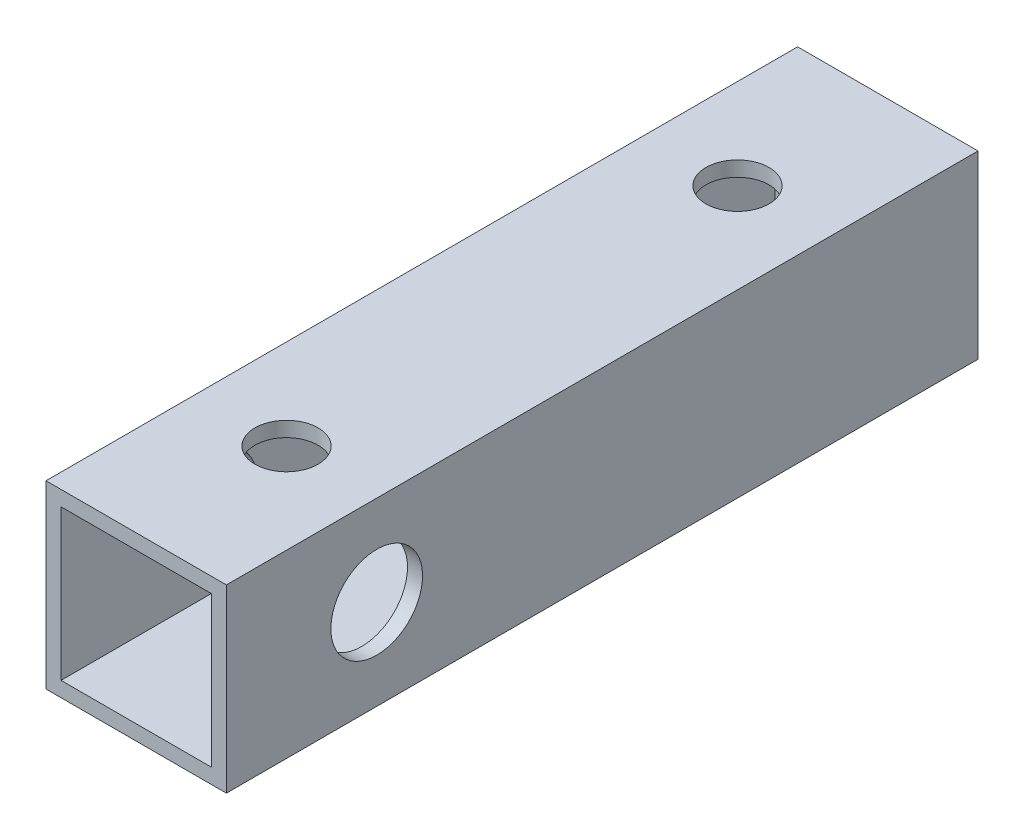
from build123d import *

# Parameters (mm, degrees)
SKETCH_1_W          = 12
SKETCH_1_H          = 12
EXTRUDE_1_DEPTH     = 50
SKETCH_2_W          = 10
SKETCH_2_H          = 10
CUT_EXTRUDE_1_DEPTH = 47.5
SKETCH_3_R          = 2.1
CUT_EXTRUDE_2_DEPTH = 47.5
SKETCH_5_R          = 3.05
CUT_EXTRUDE_4_DEPTH = 47.5


with BuildPart() as part:
    # ｽｹｯﾁ1 → ﾎﾞｽ - 押し出し1 (new body)
    with BuildSketch(Plane.XY):
        Rectangle(SKETCH_1_W, SKETCH_1_H)
    extrude(amount=EXTRUDE_1_DEPTH)

    # ｽｹｯﾁ2 → ｶｯﾄ - 押し出し1 (cut)
    with BuildSketch(Plane.XY.offset(50)):
        Rectangle(SKETCH_2_W, SKETCH_2_H)
    extrude(amount=-CUT_EXTRUDE_1_DEPTH, mode=Mode.SUBTRACT)

    # ｽｹｯﾁ3 → ｶｯﾄ - 押し出し2 (cut)
    with BuildSketch(Plane(origin=(0, 6, 0), x_dir=(1, 0, 0), z_dir=(0, 1, 0))):
        with Locations((0, -10)):
            Circle(SKETCH_3_R)
        with Locations((0, -40)):
            Circle(SKETCH_3_R)
    extrude(amount=-CUT_EXTRUDE_2_DEPTH, mode=Mode.SUBTRACT)

    # ｽｹｯﾁ5 → ｶｯﾄ - 押し出し4 (cut)
    with BuildSketch(Plane.ZY.offset(6)):
        with Locations((40, 0)):
            Circle(SKETCH_5_R)
    extrude(amount=-CUT_EXTRUDE_4_DEPTH, mode=Mode.SUBTRACT)


solid = part.part
